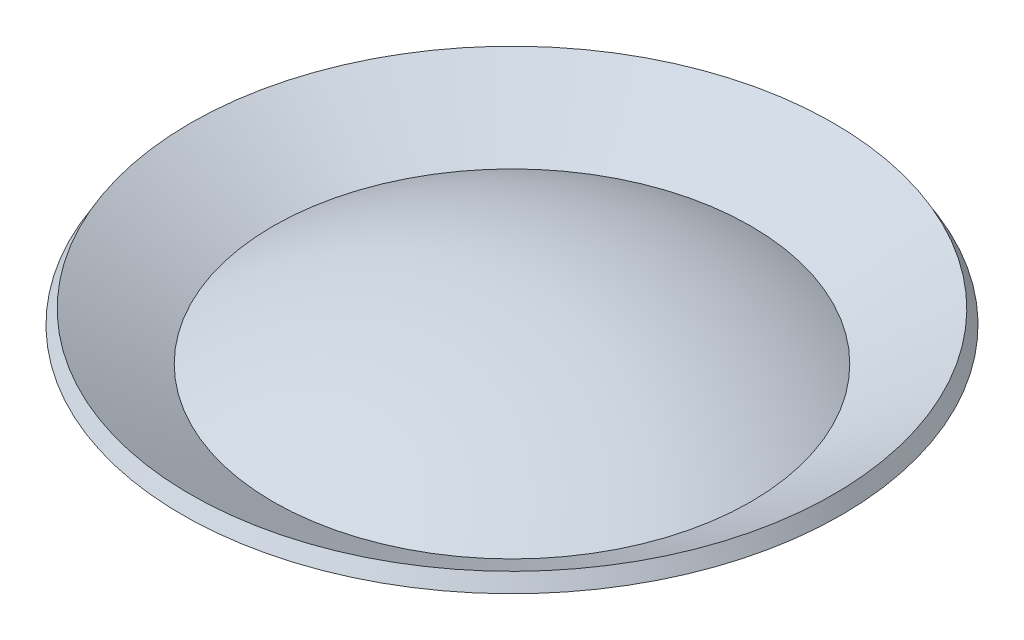
from build123d import *


with BuildPart() as part:
    # Skizze1 → Rotation1 (revolve)
    with BuildSketch(Plane.XY, mode=Mode.PRIVATE) as rotation1_sk:
        with BuildLine():
            Line((15, -4.019237886), (20.196152423, -1.019237886))
            Line((20.196152423, -1.019237886), (20.696152423, -1.88526329))
            Line((20.696152423, -1.88526329), (14.994317448, -5.177219248))
            ThreePointArc((14.994317448, -5.177219248), (7.782652446, -2.063816995), (0, -1))
            Line((0, -1), (0, 0))
            ThreePointArc((0, 0), (7.764571353, -1.022225211), (15, -4.019237886))
        make_face()
    revolve(rotation1_sk.sketch.rotate(Axis((0, 0, 0), (0, -1, 0)), 180), axis=Axis((0, 0, 0), (0, -1, 0)))  # turned: the seam where the file's is


solid = part.part
